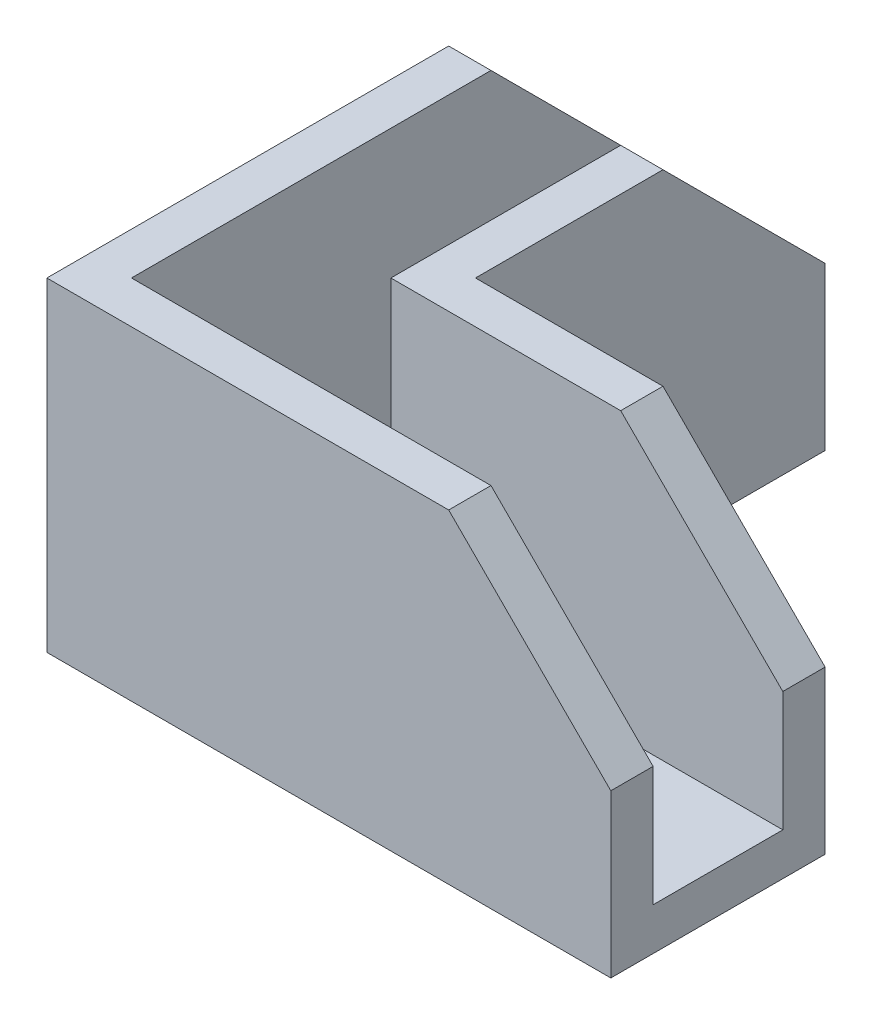
from build123d import *

# Parameters (mm, degrees)
EXTRUDE_1_DEPTH     = 3
EXTRUDE_2_DEPTH     = 20
CUT_EXTRUDE_1_DEPTH = 61
CUT_EXTRUDE_2_DEPTH = 52.137461806


with BuildPart() as part:
    # 草图1 → 凸台-拉伸1 (new body)
    with BuildSketch(Plane(origin=(0, 0, 0), x_dir=(1, 0, 0), z_dir=(0, 1, 0))):
        Polygon((40, 15.2), (15.2, 15.2), (15.2, 40), (0, 40), (0, 0), (40, 0), align=None)
    extrude(amount=-EXTRUDE_1_DEPTH)

    # 草图1<3> → 凸台-拉伸2 (add)
    with BuildSketch(Plane(origin=(0, 0, 0), x_dir=(1, 0, 0), z_dir=(0, 1, 0))):
        Polygon((40, 15.2), (15.2, 15.2), (15.2, 40), (12.2, 40), (12.2, 12.2), (40, 12.2), align=None)
        Polygon((40, 0), (40, 3), (3, 3), (3, 40), (0, 40), (0, 0), align=None)
    extrude(amount=EXTRUDE_2_DEPTH)

    # 草图2 → 切除-拉伸1 (cut, through all)
    with BuildSketch(Plane.ZY):
        Polygon((-40, 8.5), (-28.5, 20), (-40, 20), align=None)
    extrude(amount=-CUT_EXTRUDE_1_DEPTH, mode=Mode.SUBTRACT)

    # 草图3 → 切除-拉伸2 (cut, through all)
    with BuildSketch(Plane(origin=(0, 0, -15.2), x_dir=(-1, 0, 0), z_dir=(0, 0, -1))):
        Polygon((-40, 8.5), (-28.5, 20), (-40, 20), align=None)
    extrude(amount=-CUT_EXTRUDE_2_DEPTH, mode=Mode.SUBTRACT)


solid = part.part
